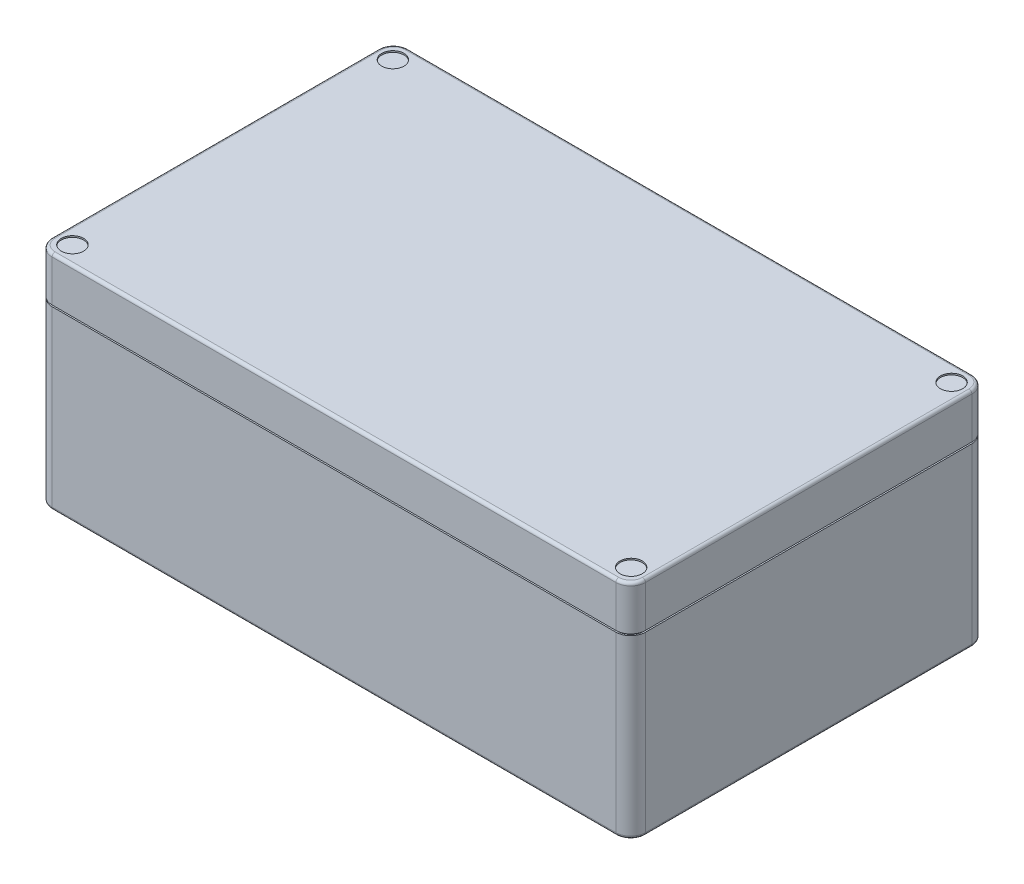
from build123d import *

# Parameters (mm, degrees)
SKETCH1_W           = 200
SKETCH1_H           = 120
BOSS_EXTRUDE1_DEPTH = 75
FILLET1_R           = 5
CUT_EXTRUDE2_DEPTH  = 0.5
SKETCH4_R           = 3.75
CUT_EXTRUDE3_DEPTH  = 0.5
FILLET2_R           = 1


with BuildPart() as part:
    # Sketch1 → Boss-Extrude1 (new body)
    with BuildSketch(Plane(origin=(0, 0, 0), x_dir=(1, 0, 0), z_dir=(0, 1, 0))):
        Rectangle(SKETCH1_W, SKETCH1_H)
    extrude(amount=BOSS_EXTRUDE1_DEPTH)

    # Fillet1
    fillet1_edges = [part.edges().sort_by_distance(p)[0] for p in [
        (-100, 37.5, -60),
        (100, 37.5, -60),
        (100, 37.5, 60),
        (-100, 37.5, 60),
    ]]
    fillet(fillet1_edges, radius=FILLET1_R)

    # Sketch3 → Cut-Extrude2 (cut)
    with BuildSketch(Plane(origin=(0, 60, 0), x_dir=(1, 0, 0), z_dir=(0, 1, 0))):
        with BuildLine():
            Line((95, 60), (-95, 60))
            ThreePointArc((-95, 60), (-98.535533906, 58.535533906), (-100, 55))
            Line((-100, 55), (-100, -55))
            ThreePointArc((-100, -55), (-98.535533906, -58.535533906), (-95, -60))
            Line((-95, -60), (95, -60))
            ThreePointArc((95, -60), (98.535533906, -58.535533906), (100, -55))
            Line((100, -55), (100, 55))
            ThreePointArc((100, 55), (98.535533906, 58.535533906), (95, 60))
        make_face()
        with BuildLine():
            Line((95, 59.5), (-95, 59.5))
            ThreePointArc((-95, 59.5), (-98.181980515, 58.181980515), (-99.5, 55))
            Line((-99.5, 55), (-99.5, -55))
            ThreePointArc((-99.5, -55), (-98.181980515, -58.181980515), (-95, -59.5))
            Line((-95, -59.5), (95, -59.5))
            ThreePointArc((95, -59.5), (98.181980515, -58.181980515), (99.5, -55))
            Line((99.5, -55), (99.5, 55))
            ThreePointArc((99.5, 55), (98.181980515, 58.181980515), (95, 59.5))
        make_face(mode=Mode.SUBTRACT)
    extrude(amount=-CUT_EXTRUDE2_DEPTH, mode=Mode.SUBTRACT)

    # Sketch4 → Cut-Extrude3 (cut)
    with BuildSketch(Plane(origin=(0, 75, 0), x_dir=(1, 0, 0), z_dir=(0, 1, 0))):
        with Locations((-94.15, 54)):
            Circle(SKETCH4_R)
        with Locations((94.15, 54)):
            Circle(SKETCH4_R)
        with Locations((94.15, -54)):
            Circle(SKETCH4_R)
        with Locations((-94.15, -54)):
            Circle(SKETCH4_R)
    extrude(amount=-CUT_EXTRUDE3_DEPTH, mode=Mode.SUBTRACT)

    # Fillet2
    fillet2_edges = [part.edges().sort_by_distance(p)[0] for p in [
        (-100, 0, 0),
        (-100, 75, 0),
        (0, 0, -60),
        (100, 0, 0),
        (0, 0, 60),
        (-98.535533906, 0, 58.535533906),
        (98.535533906, 0, 58.535533906),
        (98.535533906, 0, -58.535533906),
        (-98.535533906, 0, -58.535533906),
        (0, 75, -60),
        (0, 75, 60),
        (100, 75, 0),
        (-98.535533906, 75, 58.535533906),
        (98.535533906, 75, 58.535533906),
        (98.535533906, 75, -58.535533906),
        (-98.535533906, 75, -58.535533906),
    ]]
    fillet(fillet2_edges, radius=FILLET2_R)


solid = part.part
